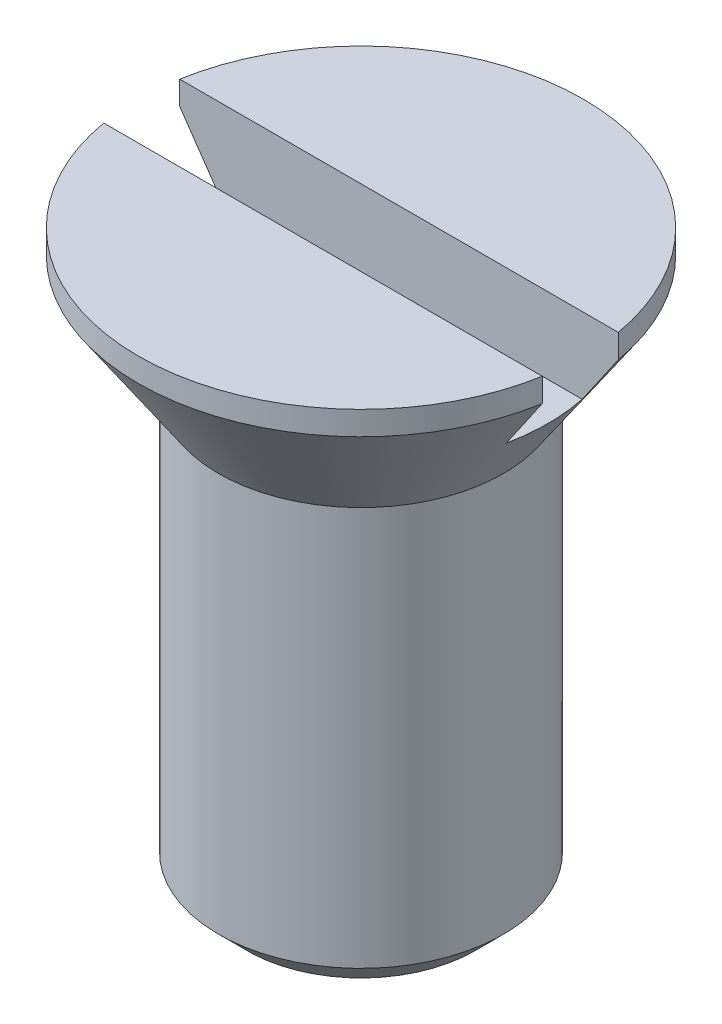
from build123d import *

# Parameters (mm, degrees)
PAH1_SIZE                  = 0.6
KES_EKSTR_ZYON1_DEPTH      = 10
KES_EKSTR_ZYON1_DEPTH_BACK = 10


with BuildPart() as part:
    # izim1 → D_nd_r1 (revolve)
    with BuildSketch(Plane.XY):
        Polygon((0, 0), (3, 0), (3, 9), (4.684504255, 11.482427323), (4.684504255, 11.982427323), (0, 11.982427323), align=None)
    revolve(axis=Axis((0, 11.982427323, 0), (0, -1, 0)))

    # Pah1
    pah1_edges = [part.edges().sort_by_distance(p)[0] for p in [
        (-3, 0, 0),
    ]]
    chamfer(pah1_edges, length=PAH1_SIZE)

    # izim2 → Kes-Ekstr_zyon1 (cut, two sides)
    with BuildSketch(Plane(origin=(0, 0, 0), x_dir=(0, 0, -1), z_dir=(1, 0, 0))) as kes_ekstr_zyon1_sk:
        Polygon((0, 11.982427323), (0.8, 11.982427323), (0.8, 10.382427323), (-0.8, 10.382427323), (-0.8, 11.982427323), align=None)
    extrude(amount=KES_EKSTR_ZYON1_DEPTH, mode=Mode.SUBTRACT)
    extrude(kes_ekstr_zyon1_sk.sketch, amount=-KES_EKSTR_ZYON1_DEPTH_BACK, mode=Mode.SUBTRACT)


solid = part.part
